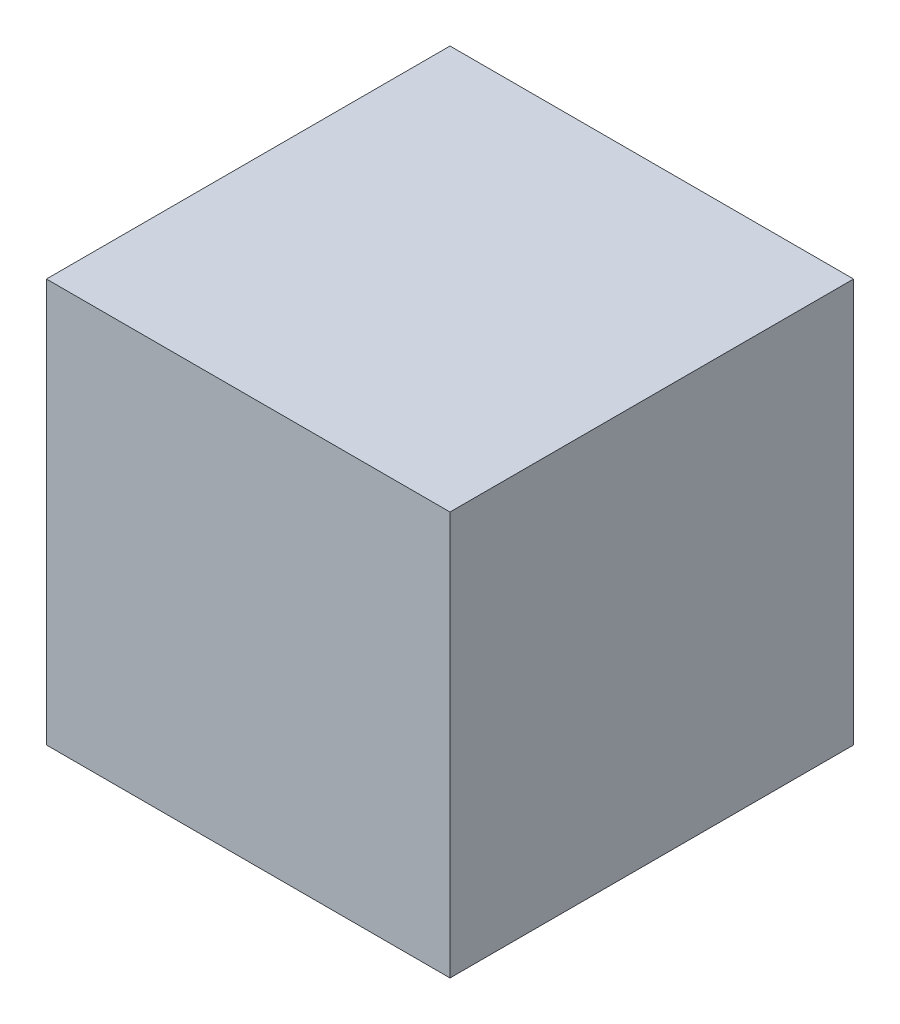
from build123d import *

# Parameters (mm, degrees)
SKIZZE1_W                       = 100
SKIZZE1_H                       = 100
AUFSATZ_LINEAR_AUSTRAGEN1_DEPTH = 100


with BuildPart() as part:
    # Skizze1 → Aufsatz-Linear austragen1 (new body)
    with BuildSketch(Plane.XY):
        with Locations((50, 50)):
            Rectangle(SKIZZE1_W, SKIZZE1_H)
    extrude(amount=AUFSATZ_LINEAR_AUSTRAGEN1_DEPTH)


solid = part.part
